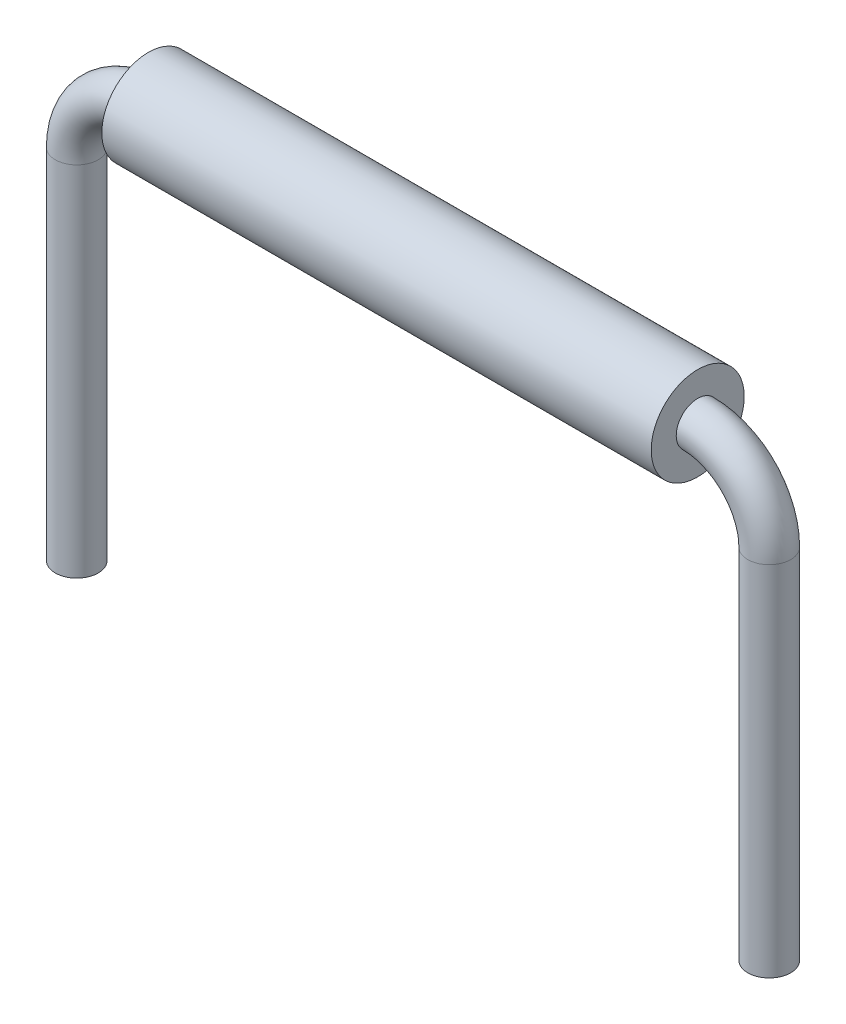
from build123d import *

# Parameters (mm, degrees)
SKETCH2_R                = 0.3
SKETCH3_R                = 0.65
SKETCH3_R_2              = 0.3
BOSS_EXTRUDE1_DEPTH      = 3.8375
BOSS_EXTRUDE1_DEPTH_BACK = 3.8375


with BuildPart() as part:
    # Sweep1: sweep along a path in Sketch1
    with BuildLine(Plane.XY) as sweep1_path:
        Line((-4.8375, -6), (-4.8375, -1))
        ThreePointArc((-4.8375, -1), (-4.544606781, -0.292893219), (-3.8375, 0))
        Line((-3.8375, 0), (3.8375, 0))
        ThreePointArc((3.8375, 0), (4.544606781, -0.292893219), (4.8375, -1))
        Line((4.8375, -1), (4.8375, -6))
    # Sketch2 → Sweep1 (sweep)
    with BuildSketch(Plane(origin=(0, 0, 0), x_dir=(0, 0, -1), z_dir=(1, 0, 0))):
        Circle(SKETCH2_R)
    sweep(path=sweep1_path.line)


with BuildPart() as body_2:
    # Sketch3 → Boss-Extrude1 (new body, two sides)
    with BuildSketch(Plane(origin=(0, 0, 0), x_dir=(0, 0, -1), z_dir=(1, 0, 0))) as boss_extrude1_sk:
        Circle(SKETCH3_R)
        Circle(SKETCH3_R_2, mode=Mode.SUBTRACT)
    extrude(amount=BOSS_EXTRUDE1_DEPTH)
    extrude(boss_extrude1_sk.sketch, amount=-BOSS_EXTRUDE1_DEPTH_BACK)


solid = Compound([part.part, body_2.part])
